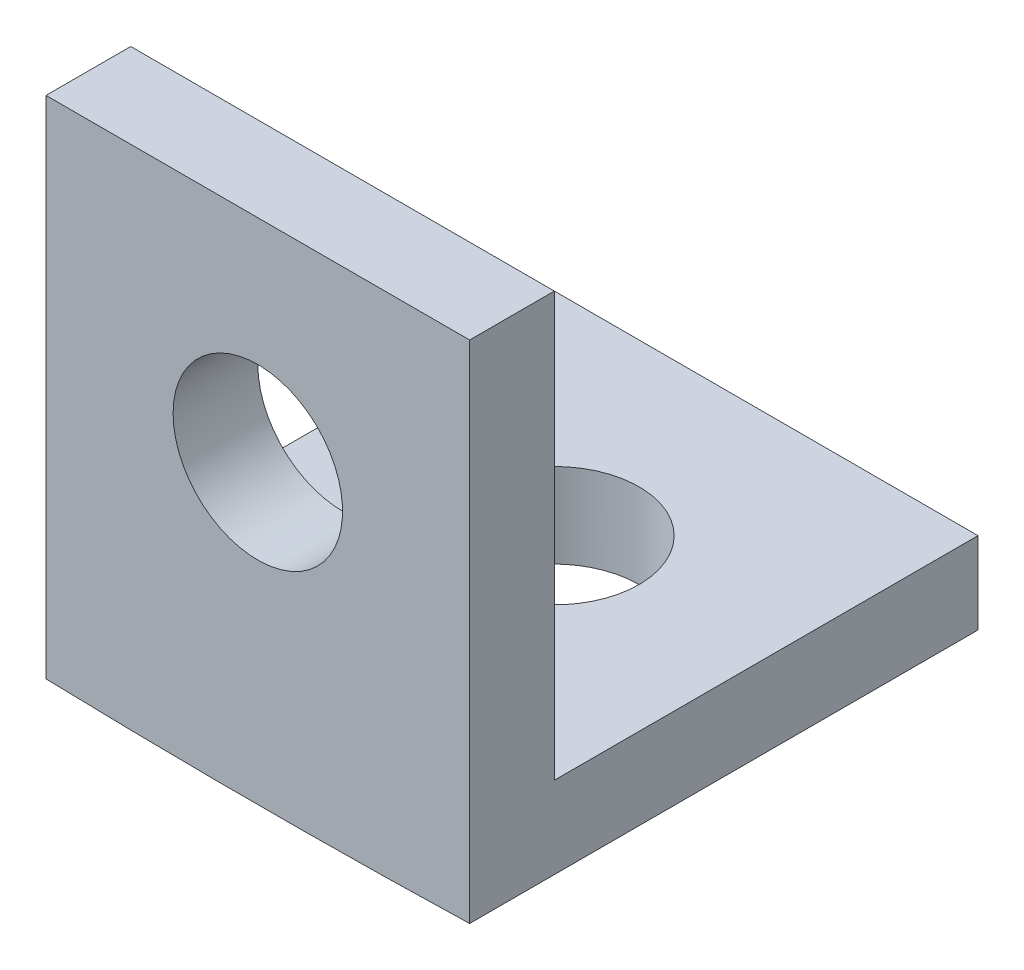
from build123d import *

# Parameters (mm, degrees)
ESBO_O1_W                = 5
ESBO_O1_H                = 6
RESSALTO_EXTRUS_O1_DEPTH = 1
ESBO_O2_W                = 5
ESBO_O2_H                = 1
RESSALTO_EXTRUS_O2_DEPTH = 5
CORTE_EXTRUS_O1_REACH    = 8
CORTE_EXTRUS_O2_REACH    = 3
ESBO_O4_R                = 1
CORTE_EXTRUS_O3_REACH    = 3
ESBO_O5_R                = 1


with BuildPart() as part:
    # Esboço1 → Ressalto-extrusão1 (new body)
    with BuildSketch(Plane.XY):
        Rectangle(ESBO_O1_W, ESBO_O1_H)
    extrude(amount=-RESSALTO_EXTRUS_O1_DEPTH)

    # Esboço2 → Ressalto-extrusão2 (add)
    with BuildSketch(Plane(origin=(0, 0, -1), x_dir=(-1, 0, 0), z_dir=(0, 0, -1))):
        with Locations((0, -2.5)):
            Rectangle(ESBO_O2_W, ESBO_O2_H)
    extrude(amount=RESSALTO_EXTRUS_O2_DEPTH)

    # Esboço3 → Corte-extrusão1 (cut, up to next)
    with BuildSketch(Plane.XY, mode=Mode.PRIVATE) as corte_extrus_o1_sk1:
        with BuildLine():
            ThreePointArc((3.35e-07, -3), (-1.250125983, -2.991119921), (-2.5, -2.964481468))
            Line((-2.5, -2.964481468), (-2.5, -3))
            Line((-2.5, -3), (3.35e-07, -3))
        make_face()
    corte_extrus_o1_tool1 = extrude(corte_extrus_o1_sk1.sketch, amount=-CORTE_EXTRUS_O1_REACH, mode=Mode.PRIVATE) & part.part
    add(corte_extrus_o1_tool1.solids().sort_by_distance((-1.875025, -2.989345, 0))[0], mode=Mode.SUBTRACT)
    # Esboço3 → Corte-extrusão1 (cut, up to next)
    with BuildSketch(Plane.XY, mode=Mode.PRIVATE) as corte_extrus_o1_sk2:
        with BuildLine():
            Line((2.5, -3), (2.5, -2.964481468))
            ThreePointArc((2.5, -2.964481468), (1.250126318, -2.991119917), (3.35e-07, -3))
            Line((3.35e-07, -3), (2.5, -3))
        make_face()
    corte_extrus_o1_tool2 = extrude(corte_extrus_o1_sk2.sketch, amount=-CORTE_EXTRUS_O1_REACH, mode=Mode.PRIVATE) & part.part
    add(corte_extrus_o1_tool2.solids().sort_by_distance((1.875025, -2.989345, 0))[0], mode=Mode.SUBTRACT)

    # Esboço4 → Corte-extrusão2 (cut, up to next)
    with BuildSketch(Plane(origin=(0, -2, 0), x_dir=(1, 0, 0), z_dir=(0, 1, 0)), mode=Mode.PRIVATE) as corte_extrus_o2_sk1:
        with Locations((0, 3.5)):
            Circle(ESBO_O4_R)
    corte_extrus_o2_tool1 = extrude(corte_extrus_o2_sk1.sketch, amount=-CORTE_EXTRUS_O2_REACH, mode=Mode.PRIVATE) & part.part
    add(corte_extrus_o2_tool1.solids().sort_by_distance((0, -2, -3.5))[0], mode=Mode.SUBTRACT)

    # Esboço5 → Corte-extrusão3 (cut, up to next)
    with BuildSketch(Plane(origin=(0, 0, -1), x_dir=(-1, 0, 0), z_dir=(0, 0, -1)), mode=Mode.PRIVATE) as corte_extrus_o3_sk1:
        with Locations((0, 0.5)):
            Circle(ESBO_O5_R)
    corte_extrus_o3_tool1 = extrude(corte_extrus_o3_sk1.sketch, amount=-CORTE_EXTRUS_O3_REACH, mode=Mode.PRIVATE) & part.part
    add(corte_extrus_o3_tool1.solids().sort_by_distance((0, 0.5, -1))[0], mode=Mode.SUBTRACT)


solid = part.part
